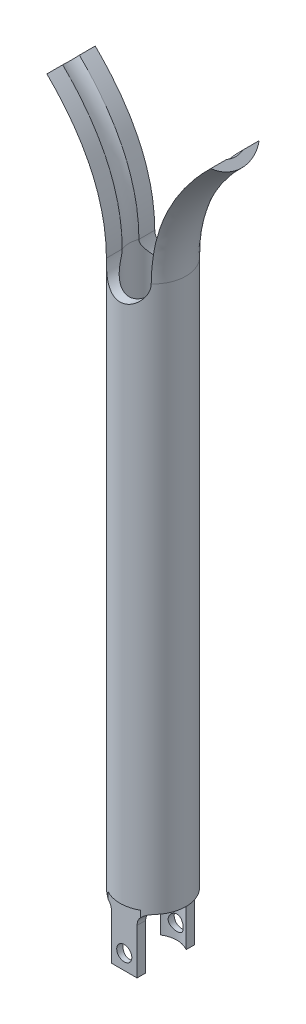
from build123d import *

# Parameters (mm, degrees)
SKETCH1_R                = 1.0922
SKETCH1_R_2              = 0.7922
EXTRUDE_THIN1_DEPTH      = 20
CUT_EXTRUDE1_DEPTH       = 26.634625129
CUT_EXTRUDE1_DEPTH_BACK  = 26.634625129
SKETCH5_R                = 0.7422
CUT_EXTRUDE3_DEPTH       = 1
SKETCH10_W               = 7.629631572
SKETCH10_H               = 1.4248156
SKETCH10_H_2             = 1.107527322
CUT_EXTRUDE5_DEPTH       = 2
CUT_EXTRUDE4_DEPTH       = 10
CUT_EXTRUDE4_DEPTH_BACK  = 10
SKETCH9_R                = 0.25
CUT_EXTRUDE10_DEPTH      = 1.5
CUT_EXTRUDE10_DEPTH_BACK = 1.5


with BuildPart() as part:
    # Sketch1 → Extrude-Thin1 (new body)
    with BuildSketch(Plane(origin=(0, 0, 0), x_dir=(1, 0, 0), z_dir=(0, 1, 0))):
        Circle(SKETCH1_R)
        Circle(SKETCH1_R_2, mode=Mode.SUBTRACT)
    extrude(amount=EXTRUDE_THIN1_DEPTH)

    # Sweep1: sweep along a path in Sketch4
    with BuildLine() as sweep1_path:  # in the path sketch's own coordinates; laid on its plane below (add() does not lay a ready-made edge on the line's plane)
        add(Edge.make_bspline(
            [(-1.0922, 20), (-1.1, 22.819845093), (-4.0922, 25)],
            knots=[0, 0, 0, 1, 1, 1], degree=2))
    # Sketch3 → Sweep1 (sweep)
    with BuildSketch(Plane(origin=(0, 20, 0), x_dir=(1, 0, 0), z_dir=(0, 1, 0))):
        with BuildLine():
            Line((-0.7422, -0.276983754), (-0.7422, -0.801273986))
            ThreePointArc((-0.7422, -0.801273986), (-1.0922, 0), (-0.7422, 0.801273986))
            Line((-0.7422, 0.801273986), (-0.7422, 0.276983754))
            ThreePointArc((-0.7422, 0.276983754), (-0.7922, 0), (-0.7422, -0.276983754))
        make_face()
    sweep1 = sweep(path=Plane.XY * sweep1_path.line)

    # Mirror1: Sweep1 across plane
    add(sweep1.mirror(Plane(origin=(0, 0, 0), x_dir=(0, 0, 1), z_dir=(1, 0, 0))))

    # Sketch5 → Cut-Extrude1 (cut, two sides: drawn at the far end of the back side and taken through both)
    with BuildSketch(Plane.XY.offset(-CUT_EXTRUDE1_DEPTH_BACK)):
        with Locations((0, 20)):
            Circle(SKETCH5_R)
    extrude(amount=CUT_EXTRUDE1_DEPTH + CUT_EXTRUDE1_DEPTH_BACK, mode=Mode.SUBTRACT)

    # Sketch7 → Cut-Extrude3 (cut, symmetric)
    with BuildSketch(Plane.XY):
        Polygon((-3.943727123, 25.376725106), (-2.695468515, 24.323621974), (-3.002892381, 23.959227952), (-4.233358336, 24.997320174), align=None)
    cut_extrude3 = extrude(amount=CUT_EXTRUDE3_DEPTH, both=True, mode=Mode.SUBTRACT)

    # Mirror2: Cut-Extrude3 across plane
    add(cut_extrude3.mirror(Plane(origin=(0, 0, 0), x_dir=(0, 0, 1), z_dir=(1, 0, 0))), mode=Mode.SUBTRACT)

    # Sketch10 → Cut-Extrude5 (cut)
    with BuildSketch(Plane.XZ):
        with Locations((0.215570245, 1.6649078)):
            Rectangle(SKETCH10_W, SKETCH10_H)
        with Locations((0.215570245, -1.506263661)):
            Rectangle(SKETCH10_W, SKETCH10_H_2)
    extrude(amount=-CUT_EXTRUDE5_DEPTH, mode=Mode.SUBTRACT)

    # Sketch9 → Cut-Extrude4 (cut, two sides: drawn at the far end of the back side and taken through both)
    with BuildSketch(Plane.XY.offset(-CUT_EXTRUDE4_DEPTH_BACK)):
        with Locations((0, 0.5)):
            Circle(SKETCH9_R)
    extrude(amount=CUT_EXTRUDE4_DEPTH + CUT_EXTRUDE4_DEPTH_BACK, mode=Mode.SUBTRACT)

    # Sketch11 → Cut-Extrude10 (cut, two sides: drawn at the far end of the back side and taken through both)
    with BuildSketch(Plane.XY.offset(-CUT_EXTRUDE10_DEPTH_BACK)):
        with BuildLine():
            Line((0.425, 1.509625), (0.425, 0))
            Line((0.425, 0), (0.425, -2.073284984))
            Line((0.425, -2.073284984), (3.393193603, 1.9065))
            Line((3.393193603, 1.9065), (0.821875, 1.9065))
            ThreePointArc((0.821875, 1.9065), (0.541241996, 1.790258004), (0.425, 1.509625))
        make_face()
        with BuildLine():
            Line((-0.821875, 1.9065), (-3.393193603, 1.9065))
            Line((-3.393193603, 1.9065), (-0.425, -3.083793411))
            Line((-0.425, -3.083793411), (-0.425, 0))
            Line((-0.425, 0), (-0.425, 1.509625))
            ThreePointArc((-0.425, 1.509625), (-0.541241996, 1.790258004), (-0.821875, 1.9065))
        make_face()
    extrude(amount=CUT_EXTRUDE10_DEPTH + CUT_EXTRUDE10_DEPTH_BACK, mode=Mode.SUBTRACT)


solid = part.part
